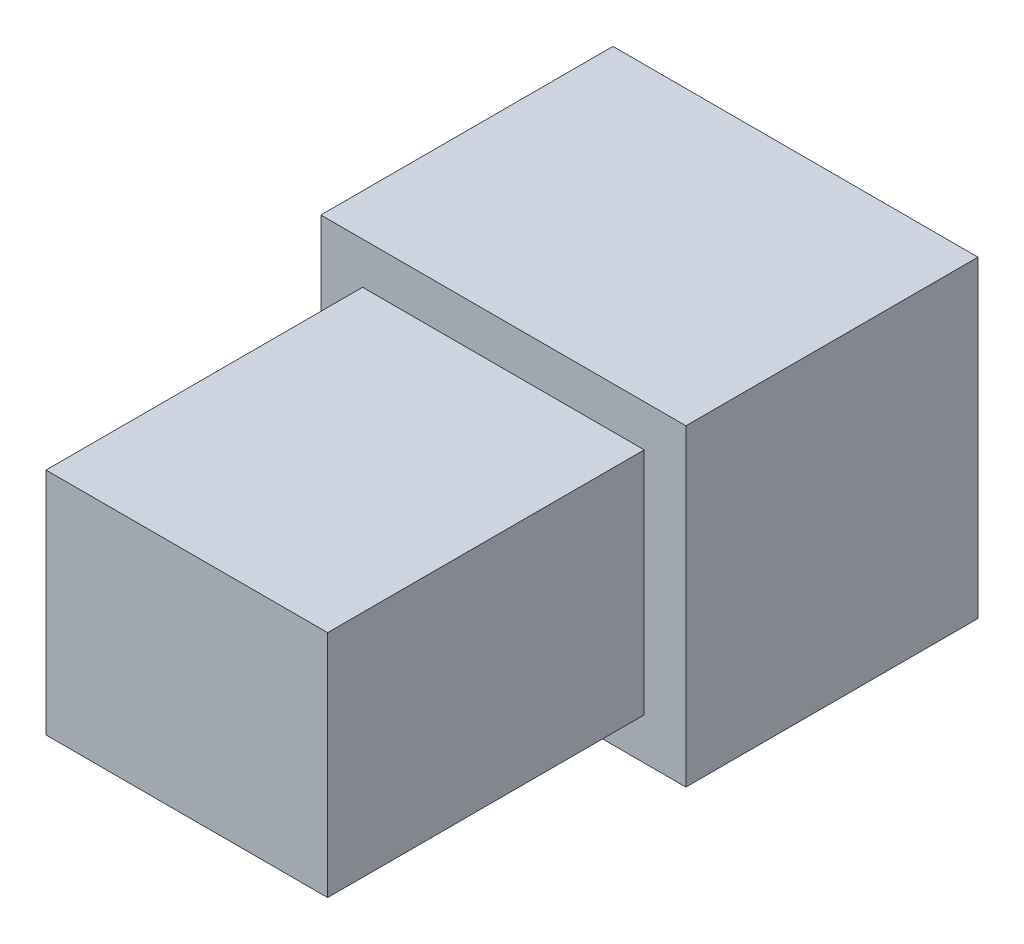
from build123d import *

# Parameters (mm, degrees)
SKETCH1_W      = 3500
SKETCH1_H      = 3000
EXTRUDE1_DEPTH = 2800
SKETCH3_W      = 2700
SKETCH3_H      = 2200
EXTRUDE2_DEPTH = 3035


with BuildPart() as part:
    # Sketch1 → Extrude1 (new body)
    with BuildSketch(Plane.XY):
        with Locations((5874, -250)):
            Rectangle(SKETCH1_W, SKETCH1_H)
    extrude(amount=EXTRUDE1_DEPTH)

    # Sketch3 → Extrude2 (add)
    with BuildSketch(Plane.XY.offset(2800)):
        with Locations((5874, -250)):
            Rectangle(SKETCH3_W, SKETCH3_H)
    extrude(amount=EXTRUDE2_DEPTH)


solid = part.part
